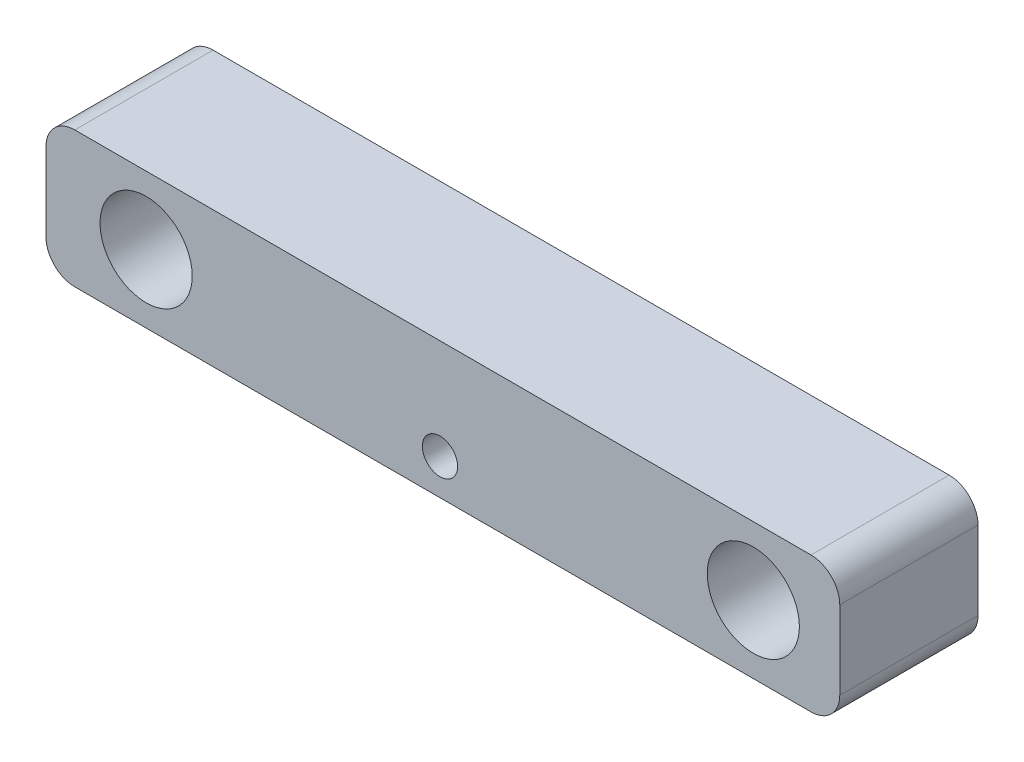
from build123d import *

# Parameters (mm, degrees)
SKETCH5_W            = 175.006
SKETCH5_H            = 29.972
SKETCH5_R            = 10.16
BOSS_EXTRUDE11_DEPTH = 30.48
SKETCH7_R            = 3.887338421
CUT_EXTRUDE6_DEPTH   = 7.62
FILLET1_R            = 6.35


with BuildPart() as part:
    # Sketch5 → Boss-Extrude11 (new body)
    with BuildSketch(Plane.XY):
        with Locations((-72.157166667, 4.66725)):
            Rectangle(SKETCH5_W, SKETCH5_H)
        with Locations((-137.583333333, 4.66725)):
            Circle(SKETCH5_R, mode=Mode.SUBTRACT)
        with Locations((-3.715568727, 4.66725)):
            Circle(SKETCH5_R, mode=Mode.SUBTRACT)
    extrude(amount=BOSS_EXTRUDE11_DEPTH)

    # Sketch7 → Cut-Extrude6 (cut)
    with BuildSketch(Plane.XY.offset(30.48)):
        with Locations((-72.793003422, -2.423465595)):
            Circle(SKETCH7_R)
    extrude(amount=-CUT_EXTRUDE6_DEPTH, mode=Mode.SUBTRACT)

    # Fillet1
    fillet1_edges = [part.edges().sort_by_distance(p)[0] for p in [
        (15.345833333, -10.31875, 15.24),
        (-159.660166667, -10.31875, 15.24),
        (-159.660166667, 19.65325, 15.24),
        (15.345833333, 19.65325, 15.24),
    ]]
    fillet(fillet1_edges, radius=FILLET1_R)


solid = part.part
